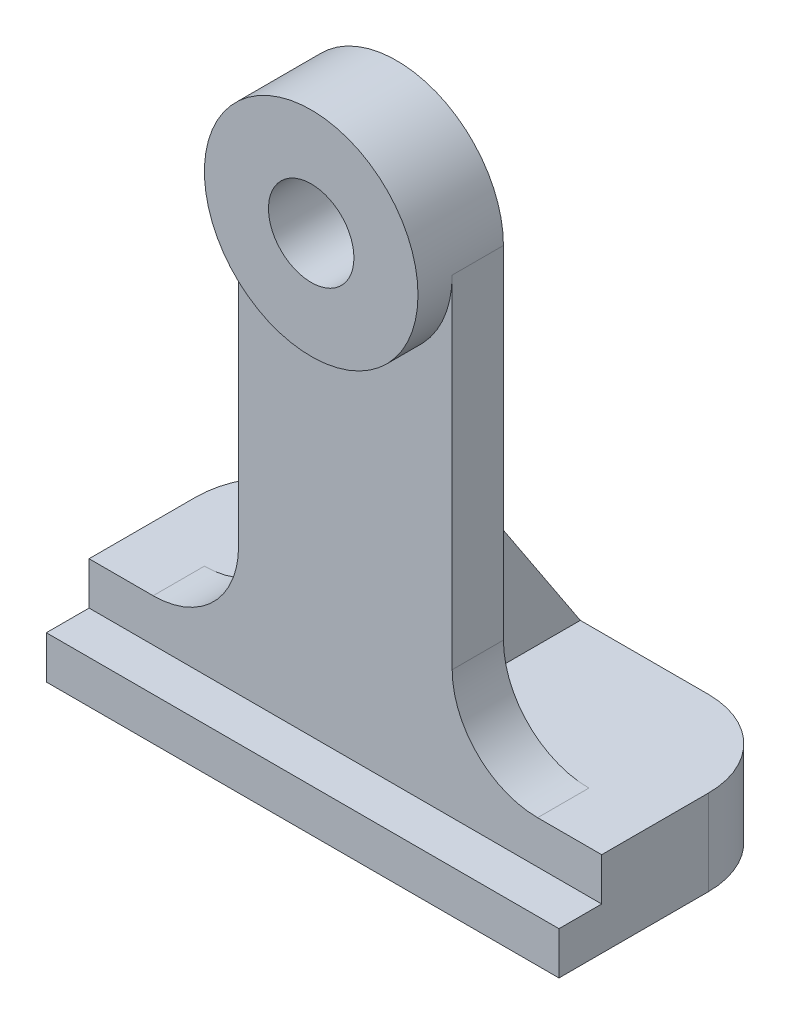
from build123d import *

# Parameters (mm, degrees)
SKETCH1_R           = 0.625
SKETCH1_R_2         = 0.25
BOSS_EXTRUDE1_DEPTH = 0.5
SKETCH2_W           = 1.25
SKETCH2_H           = 2.5
BOSS_EXTRUDE2_DEPTH = 0.3
BOSS_EXTRUDE3_DEPTH = 1.125
SKETCH4_W           = 3
SKETCH4_H           = 0.25
BOSS_EXTRUDE4_DEPTH = 0.25
SKETCH6_R           = 0.25
CUT_EXTRUDE1_DEPTH  = 0.3
FILLET1_R           = 0.5
BOSS_EXTRUDE5_DEPTH = 0.25
FILLET2_R           = 0.5


with BuildPart() as part:
    # Sketch1 → Boss-Extrude1 (new body)
    with BuildSketch(Plane.XY):
        Circle(SKETCH1_R)
        Circle(SKETCH1_R_2, mode=Mode.SUBTRACT)
    extrude(amount=BOSS_EXTRUDE1_DEPTH)

    # Sketch2 → Boss-Extrude2 (add)
    with BuildSketch(Plane.XY):
        with Locations((0, -1.25)):
            Rectangle(SKETCH2_W, SKETCH2_H)
    extrude(amount=BOSS_EXTRUDE2_DEPTH)

    # Sketch3 → Boss-Extrude3 (add)
    with BuildSketch(Plane.XY.offset(0.3)):
        Polygon((0, -2.5), (-0.625, -2.5), (-1.5, -2.5), (-1.5, -3), (1.5, -3), (1.5, -2.5), (0.625, -2.5), align=None)
    extrude(amount=-BOSS_EXTRUDE3_DEPTH)

    # Sketch4 → Boss-Extrude4 (add)
    with BuildSketch(Plane.XY.offset(0.3)):
        with Locations((0, -2.875)):
            Rectangle(SKETCH4_W, SKETCH4_H)
    extrude(amount=BOSS_EXTRUDE4_DEPTH)

    # Sketch6 → Cut-Extrude1 (cut)
    with BuildSketch(Plane.XY.offset(0.3)):
        Circle(SKETCH6_R)
    extrude(amount=-CUT_EXTRUDE1_DEPTH, mode=Mode.SUBTRACT)

    # Fillet1
    fillet1_edges = [part.edges().sort_by_distance(p)[0] for p in [
        (-0.625, -2.5, 0.15),
        (0.625, -2.5, 0.15),
    ]]
    fillet(fillet1_edges, radius=FILLET1_R)

    # Sketch7 → Boss-Extrude5 (add, symmetric)
    with BuildSketch(Plane(origin=(0, 0, 0), x_dir=(0, 0, -1), z_dir=(1, 0, 0))):
        Polygon((0, -2.5), (0, -1.25), (0.825, -2.5), align=None)
    extrude(amount=BOSS_EXTRUDE5_DEPTH, both=True)

    # Fillet2
    fillet2_edges = [part.edges().sort_by_distance(p)[0] for p in [
        (1.5, -2.75, -0.825),
        (-1.5, -2.75, -0.825),
    ]]
    fillet(fillet2_edges, radius=FILLET2_R)


solid = part.part
